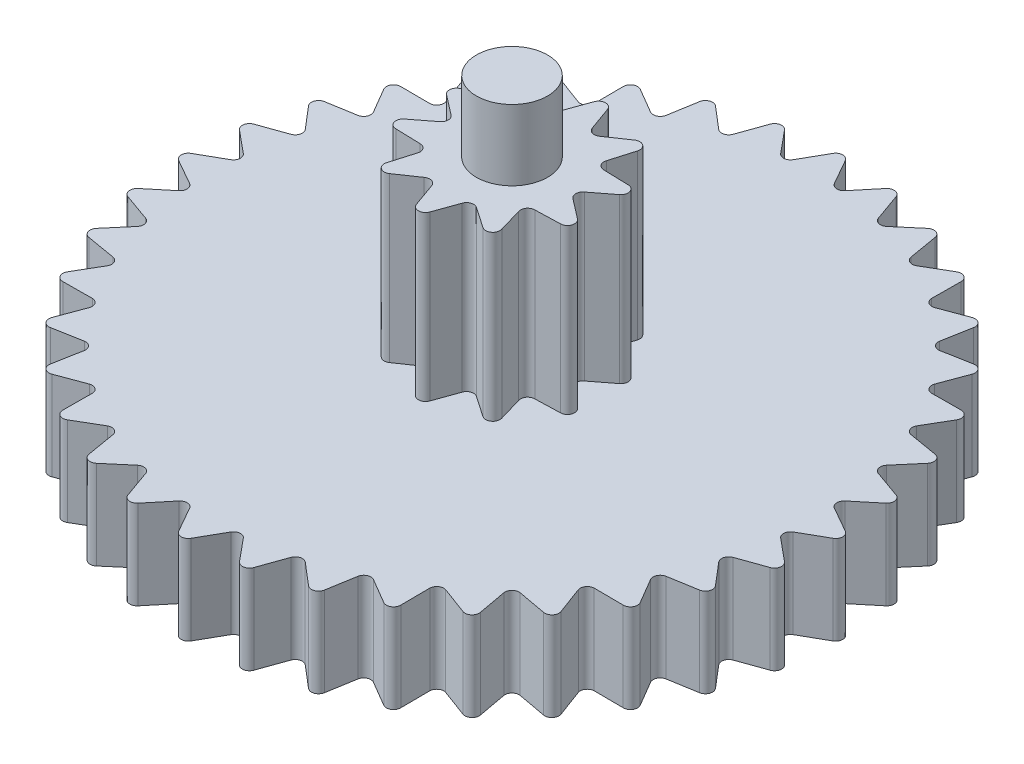
from build123d import *

# Parameters (mm, degrees)
BOSS_EXTRUDE1_DEPTH      = 2.5
SKETCH2_R                = 1
BOSS_EXTRUDE2_DEPTH      = 7.1
SKETCH3_R                = 1
BOSS_EXTRUDE3_DEPTH      = 9.08
BOSS_EXTRUDE3_DEPTH_BACK = 2.6
FILLET1_R                = 1


with BuildPart() as part:
    # Sketch1 → Boss-Extrude1 (new body)
    with BuildSketch(Plane(origin=(0, 0, 0), x_dir=(1, 0, 0), z_dir=(0, 1, 0))):
        with BuildLine():
            Line((1.42370209, 9.08258892), (0.900959127, 8.450813806))
            ThreePointArc((0.900959127, 8.450813806), (0.825205502, 8.397364753), (0.733489057, 8.383818287))
            ThreePointArc((0.733489057, 8.383818287), (0.64551831, 8.413085345), (0.580196884, 8.478876866))
            Line((0.580196884, 8.478876866), (0.175102158, 9.191827259))
            ThreePointArc((0.175102158, 9.191827259), (0, 9.295187545), (-0.175102158, 9.191827259))
            Line((-0.175102158, 9.191827259), (-0.580196884, 8.478876866))
            ThreePointArc((-0.580196884, 8.478876866), (-0.64551831, 8.413085345), (-0.733489057, 8.383818287))
            ThreePointArc((-0.733489057, 8.383818287), (-0.825205502, 8.397364753), (-0.900959127, 8.450813806))
            Line((-0.900959127, 8.450813806), (-1.42370209, 9.08258892))
            ThreePointArc((-1.42370209, 9.08258892), (-1.614092378, 9.15397276), (-1.768586015, 9.021776578))
            Line((-1.768586015, 9.021776578), (-2.043723906, 8.249313543))
            ThreePointArc((-2.043723906, 8.249313543), (-2.096628375, 8.173178596), (-2.178180478, 8.12908021))
            ThreePointArc((-2.178180478, 8.12908021), (-2.270855863, 8.126494482), (-2.35473995, 8.165977045))
            Line((-2.35473995, 8.165977045), (-2.979247871, 8.697380712))
            ThreePointArc((-2.979247871, 8.697380712), (-3.179141376, 8.734619145), (-3.308332282, 8.577603782))
            Line((-3.308332282, 8.577603782), (-3.445153411, 7.769099002))
            ThreePointArc((-3.445153411, 7.769099002), (-3.484033448, 7.684933952), (-3.556688986, 7.627344145))
            ThreePointArc((-3.556688986, 7.627344145), (-3.647507417, 7.608704788), (-3.736973192, 7.633021204))
            Line((-3.736973192, 7.633021204), (-4.444270713, 8.047906992))
            ThreePointArc((-4.444270713, 8.047906992), (-4.647593772, 8.049868547), (-4.747556546, 7.872804835))
            Line((-4.747556546, 7.872804835), (-4.741903674, 7.05282432))
            ThreePointArc((-4.741903674, 7.05282432), (-4.765577928, 6.963186478), (-4.8271293, 6.893855088))
            ThreePointArc((-4.8271293, 6.893855088), (-4.913331304, 6.85972845), (-5.005660395, 6.868139875))
            Line((-5.005660395, 6.868139875), (-5.774256638, 7.153901691))
            ThreePointArc((-5.774256638, 7.153901691), (-5.974831384, 7.120526766), (-6.042528707, 6.928794696))
            Line((-6.042528707, 6.928794696), (-5.894573592, 6.122253139))
            ThreePointArc((-5.894573592, 6.122253139), (-5.902322733, 6.029866106), (-5.950899733, 5.950899733))
            ThreePointArc((-5.950899733, 5.950899733), (-6.029866106, 5.902322733), (-6.122253139, 5.894573592))
            Line((-6.122253139, 5.894573592), (-6.928794696, 6.042528707))
            ThreePointArc((-6.928794696, 6.042528707), (-7.120526766, 5.974831384), (-7.153901691, 5.774256638))
            Line((-7.153901691, 5.774256638), (-6.868139875, 5.005660395))
            ThreePointArc((-6.868139875, 5.005660395), (-6.85972845, 4.913331304), (-6.893855088, 4.8271293))
            ThreePointArc((-6.893855088, 4.8271293), (-6.963186478, 4.765577928), (-7.05282432, 4.741903674))
            Line((-7.05282432, 4.741903674), (-7.872804835, 4.747556546))
            ThreePointArc((-7.872804835, 4.747556546), (-8.049868547, 4.647593772), (-8.047906992, 4.444270713))
            Line((-8.047906992, 4.444270713), (-7.633021204, 3.736973192))
            ThreePointArc((-7.633021204, 3.736973192), (-7.608704788, 3.647507417), (-7.627344145, 3.556688986))
            ThreePointArc((-7.627344145, 3.556688986), (-7.684933952, 3.484033448), (-7.769099002, 3.445153411))
            Line((-7.769099002, 3.445153411), (-8.577603782, 3.308332282))
            ThreePointArc((-8.577603782, 3.308332282), (-8.734619145, 3.179141376), (-8.697380712, 2.979247871))
            Line((-8.697380712, 2.979247871), (-8.165977045, 2.35473995))
            ThreePointArc((-8.165977045, 2.35473995), (-8.126494482, 2.270855863), (-8.12908021, 2.178180478))
            ThreePointArc((-8.12908021, 2.178180478), (-8.173178596, 2.096628375), (-8.249313543, 2.043723906))
            Line((-8.249313543, 2.043723906), (-9.021776578, 1.768586015))
            ThreePointArc((-9.021776578, 1.768586015), (-9.15397276, 1.614092378), (-9.08258892, 1.42370209))
            Line((-9.08258892, 1.42370209), (-8.450813806, 0.900959127))
            ThreePointArc((-8.450813806, 0.900959127), (-8.397364753, 0.825205502), (-8.383818287, 0.733489057))
            ThreePointArc((-8.383818287, 0.733489057), (-8.413085345, 0.64551831), (-8.478876866, 0.580196884))
            Line((-8.478876866, 0.580196884), (-9.191827259, 0.175102158))
            ThreePointArc((-9.191827259, 0.175102158), (-9.295187545, 0), (-9.191827259, -0.175102158))
            Line((-9.191827259, -0.175102158), (-8.478876866, -0.580196884))
            ThreePointArc((-8.478876866, -0.580196884), (-8.413085345, -0.64551831), (-8.383818287, -0.733489057))
            ThreePointArc((-8.383818287, -0.733489057), (-8.397364753, -0.825205502), (-8.450813806, -0.900959127))
            Line((-8.450813806, -0.900959127), (-9.08258892, -1.42370209))
            ThreePointArc((-9.08258892, -1.42370209), (-9.15397276, -1.614092378), (-9.021776578, -1.768586015))
            Line((-9.021776578, -1.768586015), (-8.249313543, -2.043723906))
            ThreePointArc((-8.249313543, -2.043723906), (-8.173178596, -2.096628375), (-8.12908021, -2.178180478))
            ThreePointArc((-8.12908021, -2.178180478), (-8.126494482, -2.270855863), (-8.165977045, -2.35473995))
            Line((-8.165977045, -2.35473995), (-8.697380712, -2.979247871))
            ThreePointArc((-8.697380712, -2.979247871), (-8.734619145, -3.179141376), (-8.577603782, -3.308332282))
            Line((-8.577603782, -3.308332282), (-7.769099002, -3.445153411))
            ThreePointArc((-7.769099002, -3.445153411), (-7.684933952, -3.484033448), (-7.627344145, -3.556688986))
            ThreePointArc((-7.627344145, -3.556688986), (-7.608704788, -3.647507417), (-7.633021204, -3.736973192))
            Line((-7.633021204, -3.736973192), (-8.047906992, -4.444270713))
            ThreePointArc((-8.047906992, -4.444270713), (-8.049868547, -4.647593772), (-7.872804835, -4.747556546))
            Line((-7.872804835, -4.747556546), (-7.05282432, -4.741903674))
            ThreePointArc((-7.05282432, -4.741903674), (-6.963186478, -4.765577928), (-6.893855088, -4.8271293))
            ThreePointArc((-6.893855088, -4.8271293), (-6.85972845, -4.913331304), (-6.868139875, -5.005660395))
            Line((-6.868139875, -5.005660395), (-7.153901691, -5.774256638))
            ThreePointArc((-7.153901691, -5.774256638), (-7.120526766, -5.974831384), (-6.928794696, -6.042528707))
            Line((-6.928794696, -6.042528707), (-6.122253139, -5.894573592))
            ThreePointArc((-6.122253139, -5.894573592), (-6.029866106, -5.902322733), (-5.950899733, -5.950899733))
            ThreePointArc((-5.950899733, -5.950899733), (-5.902322733, -6.029866106), (-5.894573592, -6.122253139))
            Line((-5.894573592, -6.122253139), (-6.042528707, -6.928794696))
            ThreePointArc((-6.042528707, -6.928794696), (-5.974831384, -7.120526766), (-5.774256638, -7.153901691))
            Line((-5.774256638, -7.153901691), (-5.005660395, -6.868139875))
            ThreePointArc((-5.005660395, -6.868139875), (-4.913331304, -6.85972845), (-4.8271293, -6.893855088))
            ThreePointArc((-4.8271293, -6.893855088), (-4.765577928, -6.963186478), (-4.741903674, -7.05282432))
            Line((-4.741903674, -7.05282432), (-4.747556546, -7.872804835))
            ThreePointArc((-4.747556546, -7.872804835), (-4.647593772, -8.049868547), (-4.444270713, -8.047906992))
            Line((-4.444270713, -8.047906992), (-3.736973192, -7.633021204))
            ThreePointArc((-3.736973192, -7.633021204), (-3.647507417, -7.608704788), (-3.556688986, -7.627344145))
            ThreePointArc((-3.556688986, -7.627344145), (-3.484033448, -7.684933952), (-3.445153411, -7.769099002))
            Line((-3.445153411, -7.769099002), (-3.308332282, -8.577603782))
            ThreePointArc((-3.308332282, -8.577603782), (-3.179141376, -8.734619145), (-2.979247871, -8.697380712))
            Line((-2.979247871, -8.697380712), (-2.35473995, -8.165977045))
            ThreePointArc((-2.35473995, -8.165977045), (-2.270855863, -8.126494482), (-2.178180478, -8.12908021))
            ThreePointArc((-2.178180478, -8.12908021), (-2.096628375, -8.173178596), (-2.043723906, -8.249313543))
            Line((-2.043723906, -8.249313543), (-1.768586015, -9.021776578))
            ThreePointArc((-1.768586015, -9.021776578), (-1.614092378, -9.15397276), (-1.42370209, -9.08258892))
            Line((-1.42370209, -9.08258892), (-0.900959127, -8.450813806))
            ThreePointArc((-0.900959127, -8.450813806), (-0.825205502, -8.397364753), (-0.733489057, -8.383818287))
            ThreePointArc((-0.733489057, -8.383818287), (-0.64551831, -8.413085345), (-0.580196884, -8.478876866))
            Line((-0.580196884, -8.478876866), (-0.175102158, -9.191827259))
            ThreePointArc((-0.175102158, -9.191827259), (0, -9.295187545), (0.175102158, -9.191827259))
            Line((0.175102158, -9.191827259), (0.580196884, -8.478876866))
            ThreePointArc((0.580196884, -8.478876866), (0.64551831, -8.413085345), (0.733489057, -8.383818287))
            ThreePointArc((0.733489057, -8.383818287), (0.825205502, -8.397364753), (0.900959127, -8.450813806))
            Line((0.900959127, -8.450813806), (1.42370209, -9.08258892))
            ThreePointArc((1.42370209, -9.08258892), (1.614092378, -9.15397276), (1.768586015, -9.021776578))
            Line((1.768586015, -9.021776578), (2.043723906, -8.249313543))
            ThreePointArc((2.043723906, -8.249313543), (2.096628375, -8.173178596), (2.178180478, -8.12908021))
            ThreePointArc((2.178180478, -8.12908021), (2.270855863, -8.126494482), (2.35473995, -8.165977045))
            Line((2.35473995, -8.165977045), (2.979247871, -8.697380712))
            ThreePointArc((2.979247871, -8.697380712), (3.179141376, -8.734619145), (3.308332282, -8.577603782))
            Line((3.308332282, -8.577603782), (3.445153411, -7.769099002))
            ThreePointArc((3.445153411, -7.769099002), (3.484033448, -7.684933952), (3.556688986, -7.627344145))
            ThreePointArc((3.556688986, -7.627344145), (3.647507417, -7.608704788), (3.736973192, -7.633021204))
            Line((3.736973192, -7.633021204), (4.444270713, -8.047906992))
            ThreePointArc((4.444270713, -8.047906992), (4.647593772, -8.049868547), (4.747556546, -7.872804835))
            Line((4.747556546, -7.872804835), (4.741903674, -7.05282432))
            ThreePointArc((4.741903674, -7.05282432), (4.765577928, -6.963186478), (4.8271293, -6.893855088))
            ThreePointArc((4.8271293, -6.893855088), (4.913331304, -6.85972845), (5.005660395, -6.868139875))
            Line((5.005660395, -6.868139875), (5.774256638, -7.153901691))
            ThreePointArc((5.774256638, -7.153901691), (5.974831384, -7.120526766), (6.042528707, -6.928794696))
            Line((6.042528707, -6.928794696), (5.894573592, -6.122253139))
            ThreePointArc((5.894573592, -6.122253139), (5.902322733, -6.029866106), (5.950899733, -5.950899733))
            ThreePointArc((5.950899733, -5.950899733), (6.029866106, -5.902322733), (6.122253139, -5.894573592))
            Line((6.122253139, -5.894573592), (6.928794696, -6.042528707))
            ThreePointArc((6.928794696, -6.042528707), (7.120526766, -5.974831384), (7.153901691, -5.774256638))
            Line((7.153901691, -5.774256638), (6.868139875, -5.005660395))
            ThreePointArc((6.868139875, -5.005660395), (6.85972845, -4.913331304), (6.893855088, -4.8271293))
            ThreePointArc((6.893855088, -4.8271293), (6.963186478, -4.765577928), (7.05282432, -4.741903674))
            Line((7.05282432, -4.741903674), (7.872804835, -4.747556546))
            ThreePointArc((7.872804835, -4.747556546), (8.049868547, -4.647593772), (8.047906992, -4.444270713))
            Line((8.047906992, -4.444270713), (7.633021204, -3.736973192))
            ThreePointArc((7.633021204, -3.736973192), (7.608704788, -3.647507417), (7.627344145, -3.556688986))
            ThreePointArc((7.627344145, -3.556688986), (7.684933952, -3.484033448), (7.769099002, -3.445153411))
            Line((7.769099002, -3.445153411), (8.577603782, -3.308332282))
            ThreePointArc((8.577603782, -3.308332282), (8.734619145, -3.179141376), (8.697380712, -2.979247871))
            Line((8.697380712, -2.979247871), (8.165977045, -2.35473995))
            ThreePointArc((8.165977045, -2.35473995), (8.126494482, -2.270855863), (8.12908021, -2.178180478))
            ThreePointArc((8.12908021, -2.178180478), (8.173178596, -2.096628375), (8.249313543, -2.043723906))
            Line((8.249313543, -2.043723906), (9.021776578, -1.768586015))
            ThreePointArc((9.021776578, -1.768586015), (9.15397276, -1.614092378), (9.08258892, -1.42370209))
            Line((9.08258892, -1.42370209), (8.450813806, -0.900959127))
            ThreePointArc((8.450813806, -0.900959127), (8.397364753, -0.825205502), (8.383818287, -0.733489057))
            ThreePointArc((8.383818287, -0.733489057), (8.413085345, -0.64551831), (8.478876866, -0.580196884))
            Line((8.478876866, -0.580196884), (9.191827259, -0.175102158))
            ThreePointArc((9.191827259, -0.175102158), (9.295187545, 0), (9.191827259, 0.175102158))
            Line((9.191827259, 0.175102158), (8.478876866, 0.580196884))
            ThreePointArc((8.478876866, 0.580196884), (8.413085345, 0.64551831), (8.383818287, 0.733489057))
            ThreePointArc((8.383818287, 0.733489057), (8.397364753, 0.825205502), (8.450813806, 0.900959127))
            Line((8.450813806, 0.900959127), (9.08258892, 1.42370209))
            ThreePointArc((9.08258892, 1.42370209), (9.15397276, 1.614092378), (9.021776578, 1.768586015))
            Line((9.021776578, 1.768586015), (8.249313543, 2.043723906))
            ThreePointArc((8.249313543, 2.043723906), (8.173178596, 2.096628375), (8.12908021, 2.178180478))
            ThreePointArc((8.12908021, 2.178180478), (8.126494482, 2.270855863), (8.165977045, 2.35473995))
            Line((8.165977045, 2.35473995), (8.697380712, 2.979247871))
            ThreePointArc((8.697380712, 2.979247871), (8.734619145, 3.179141376), (8.577603782, 3.308332282))
            Line((8.577603782, 3.308332282), (7.769099002, 3.445153411))
            ThreePointArc((7.769099002, 3.445153411), (7.684933952, 3.484033448), (7.627344145, 3.556688986))
            ThreePointArc((7.627344145, 3.556688986), (7.608704788, 3.647507417), (7.633021204, 3.736973192))
            Line((7.633021204, 3.736973192), (8.047906992, 4.444270713))
            ThreePointArc((8.047906992, 4.444270713), (8.049868547, 4.647593772), (7.872804835, 4.747556546))
            Line((7.872804835, 4.747556546), (7.05282432, 4.741903674))
            ThreePointArc((7.05282432, 4.741903674), (6.963186478, 4.765577928), (6.893855088, 4.8271293))
            ThreePointArc((6.893855088, 4.8271293), (6.85972845, 4.913331304), (6.868139875, 5.005660395))
            Line((6.868139875, 5.005660395), (7.153901691, 5.774256638))
            ThreePointArc((7.153901691, 5.774256638), (7.120526766, 5.974831384), (6.928794696, 6.042528707))
            Line((6.928794696, 6.042528707), (6.122253139, 5.894573592))
            ThreePointArc((6.122253139, 5.894573592), (6.029866106, 5.902322733), (5.950899733, 5.950899733))
            ThreePointArc((5.950899733, 5.950899733), (5.902322733, 6.029866106), (5.894573592, 6.122253139))
            Line((5.894573592, 6.122253139), (6.042528707, 6.928794696))
            ThreePointArc((6.042528707, 6.928794696), (5.974831384, 7.120526766), (5.774256638, 7.153901691))
            Line((5.774256638, 7.153901691), (5.005660395, 6.868139875))
            ThreePointArc((5.005660395, 6.868139875), (4.913331304, 6.85972845), (4.8271293, 6.893855088))
            ThreePointArc((4.8271293, 6.893855088), (4.765577928, 6.963186478), (4.741903674, 7.05282432))
            Line((4.741903674, 7.05282432), (4.747556546, 7.872804835))
            ThreePointArc((4.747556546, 7.872804835), (4.647593772, 8.049868547), (4.444270713, 8.047906992))
            Line((4.444270713, 8.047906992), (3.736973192, 7.633021204))
            ThreePointArc((3.736973192, 7.633021204), (3.647507417, 7.608704788), (3.556688986, 7.627344145))
            ThreePointArc((3.556688986, 7.627344145), (3.484033448, 7.684933952), (3.445153411, 7.769099002))
            Line((3.445153411, 7.769099002), (3.308332282, 8.577603782))
            ThreePointArc((3.308332282, 8.577603782), (3.179141376, 8.734619145), (2.979247871, 8.697380712))
            Line((2.979247871, 8.697380712), (2.35473995, 8.165977045))
            ThreePointArc((2.35473995, 8.165977045), (2.270855863, 8.126494482), (2.178180478, 8.12908021))
            ThreePointArc((2.178180478, 8.12908021), (2.096628375, 8.173178596), (2.043723906, 8.249313543))
            Line((2.043723906, 8.249313543), (1.768586015, 9.021776578))
            ThreePointArc((1.768586015, 9.021776578), (1.614092378, 9.15397276), (1.42370209, 9.08258892))
        make_face()
        with BuildLine():
            Line((-0.189393176, 2.492919805), (-0.425136188, 1.833810381))
            ThreePointArc((-0.425136188, 1.833810381), (-0.473882898, 1.753634678), (-0.55383033, 1.704514488))
            ThreePointArc((-0.55383033, 1.704514488), (-0.647381284, 1.697261635), (-0.733944297, 1.733472544))
            Line((-0.733944297, 1.733472544), (-1.312079198, 2.128137003))
            ThreePointArc((-1.312079198, 2.128137003), (-1.545083454, 2.126624932), (-1.618523794, 1.905491972))
            Line((-1.618523794, 1.905491972), (-1.421829099, 1.233694981))
            ThreePointArc((-1.421829099, 1.233694981), (-1.41413992, 1.140178878), (-1.449946627, 1.053447888))
            ThreePointArc((-1.449946627, 1.053447888), (-1.521367819, 0.992592335), (-1.612683006, 0.971007114))
            Line((-1.612683006, 0.971007114), (-2.312381915, 0.950478199))
            ThreePointArc((-2.312381915, 0.950478199), (-2.499997545, 0.812298443), (-2.429433335, 0.590230971))
            Line((-2.429433335, 0.590230971), (-1.87543162, 0.16235003))
            ThreePointArc((-1.87543162, 0.16235003), (-1.814243557, 0.0912135), (-1.792232594, 0))
            ThreePointArc((-1.792232594, 0), (-1.814243557, -0.0912135), (-1.87543162, -0.16235003))
            Line((-1.87543162, -0.16235003), (-2.429433335, -0.590230971))
            ThreePointArc((-2.429433335, -0.590230971), (-2.499997545, -0.812298443), (-2.312381915, -0.950478199))
            Line((-2.312381915, -0.950478199), (-1.612683006, -0.971007114))
            ThreePointArc((-1.612683006, -0.971007114), (-1.521367819, -0.992592335), (-1.449946627, -1.053447888))
            ThreePointArc((-1.449946627, -1.053447888), (-1.41413992, -1.140178878), (-1.421829099, -1.233694981))
            Line((-1.421829099, -1.233694981), (-1.618523794, -1.905491972))
            ThreePointArc((-1.618523794, -1.905491972), (-1.545083454, -2.126624932), (-1.312079198, -2.128137003))
            Line((-1.312079198, -2.128137003), (-0.733944297, -1.733472544))
            ThreePointArc((-0.733944297, -1.733472544), (-0.647381284, -1.697261635), (-0.55383033, -1.704514488))
            ThreePointArc((-0.55383033, -1.704514488), (-0.473882898, -1.753634678), (-0.425136188, -1.833810381))
            Line((-0.425136188, -1.833810381), (-0.189393176, -2.492919805))
            ThreePointArc((-0.189393176, -2.492919805), (0, -2.628652979), (0.189393176, -2.492919805))
            Line((0.189393176, -2.492919805), (0.425136188, -1.833810381))
            ThreePointArc((0.425136188, -1.833810381), (0.473882898, -1.753634678), (0.55383033, -1.704514488))
            ThreePointArc((0.55383033, -1.704514488), (0.647381284, -1.697261635), (0.733944297, -1.733472544))
            Line((0.733944297, -1.733472544), (1.312079198, -2.128137003))
            ThreePointArc((1.312079198, -2.128137003), (1.545083454, -2.126624932), (1.618523794, -1.905491972))
            Line((1.618523794, -1.905491972), (1.421829099, -1.233694981))
            ThreePointArc((1.421829099, -1.233694981), (1.41413992, -1.140178878), (1.449946627, -1.053447888))
            ThreePointArc((1.449946627, -1.053447888), (1.521367819, -0.992592335), (1.612683006, -0.971007114))
            Line((1.612683006, -0.971007114), (2.312381915, -0.950478199))
            ThreePointArc((2.312381915, -0.950478199), (2.499997545, -0.812298443), (2.429433335, -0.590230971))
            Line((2.429433335, -0.590230971), (1.87543162, -0.16235003))
            ThreePointArc((1.87543162, -0.16235003), (1.814243557, -0.0912135), (1.792232594, 0))
            ThreePointArc((1.792232594, 0), (1.814243557, 0.0912135), (1.87543162, 0.16235003))
            Line((1.87543162, 0.16235003), (2.429433335, 0.590230971))
            ThreePointArc((2.429433335, 0.590230971), (2.499997545, 0.812298443), (2.312381915, 0.950478199))
            Line((2.312381915, 0.950478199), (1.612683006, 0.971007114))
            ThreePointArc((1.612683006, 0.971007114), (1.521367819, 0.992592335), (1.449946627, 1.053447888))
            ThreePointArc((1.449946627, 1.053447888), (1.41413992, 1.140178878), (1.421829099, 1.233694981))
            Line((1.421829099, 1.233694981), (1.618523794, 1.905491972))
            ThreePointArc((1.618523794, 1.905491972), (1.545083454, 2.126624932), (1.312079198, 2.128137003))
            Line((1.312079198, 2.128137003), (0.733944297, 1.733472544))
            ThreePointArc((0.733944297, 1.733472544), (0.647381284, 1.697261635), (0.55383033, 1.704514488))
            ThreePointArc((0.55383033, 1.704514488), (0.473882898, 1.753634678), (0.425136188, 1.833810381))
            Line((0.425136188, 1.833810381), (0.189393176, 2.492919805))
            ThreePointArc((0.189393176, 2.492919805), (0, 2.628652979), (-0.189393176, 2.492919805))
        make_face(mode=Mode.SUBTRACT)
    extrude(amount=BOSS_EXTRUDE1_DEPTH)

    # Sketch2 → Boss-Extrude2 (add)
    with BuildSketch(Plane(origin=(0, 0, 0), x_dir=(1, 0, 0), z_dir=(0, 1, 0))):
        with BuildLine():
            Line((-2.429433335, 0.590230971), (-1.87543162, 0.16235003))
            ThreePointArc((-1.87543162, 0.16235003), (-1.792232594, 0), (-1.87543162, -0.16235003))
            Line((-1.87543162, -0.16235003), (-2.429433335, -0.590230971))
            ThreePointArc((-2.429433335, -0.590230971), (-2.499997545, -0.812298443), (-2.312381915, -0.950478199))
            Line((-2.312381915, -0.950478199), (-1.612683006, -0.971007114))
            ThreePointArc((-1.612683006, -0.971007114), (-1.449946627, -1.053447888), (-1.421829099, -1.233694981))
            Line((-1.421829099, -1.233694981), (-1.618523794, -1.905491972))
            ThreePointArc((-1.618523794, -1.905491972), (-1.545083454, -2.126624932), (-1.312079198, -2.128137003))
            Line((-1.312079198, -2.128137003), (-0.733944297, -1.733472544))
            ThreePointArc((-0.733944297, -1.733472544), (-0.55383033, -1.704514488), (-0.425136188, -1.833810381))
            Line((-0.425136188, -1.833810381), (-0.189393176, -2.492919805))
            ThreePointArc((-0.189393176, -2.492919805), (0, -2.628652979), (0.189393176, -2.492919805))
            Line((0.189393176, -2.492919805), (0.425136188, -1.833810381))
            ThreePointArc((0.425136188, -1.833810381), (0.55383033, -1.704514488), (0.733944297, -1.733472544))
            Line((0.733944297, -1.733472544), (1.312079198, -2.128137003))
            ThreePointArc((1.312079198, -2.128137003), (1.545083454, -2.126624932), (1.618523794, -1.905491972))
            Line((1.618523794, -1.905491972), (1.421829099, -1.233694981))
            ThreePointArc((1.421829099, -1.233694981), (1.449946627, -1.053447888), (1.612683006, -0.971007114))
            Line((1.612683006, -0.971007114), (2.312381915, -0.950478199))
            ThreePointArc((2.312381915, -0.950478199), (2.499997545, -0.812298443), (2.429433335, -0.590230971))
            Line((2.429433335, -0.590230971), (1.87543162, -0.16235003))
            ThreePointArc((1.87543162, -0.16235003), (1.792232594, 0), (1.87543162, 0.16235003))
            Line((1.87543162, 0.16235003), (2.429433335, 0.590230971))
            ThreePointArc((2.429433335, 0.590230971), (2.499997545, 0.812298443), (2.312381915, 0.950478199))
            Line((2.312381915, 0.950478199), (1.612683006, 0.971007114))
            ThreePointArc((1.612683006, 0.971007114), (1.449946627, 1.053447888), (1.421829099, 1.233694981))
            Line((1.421829099, 1.233694981), (1.618523794, 1.905491972))
            ThreePointArc((1.618523794, 1.905491972), (1.545083454, 2.126624932), (1.312079198, 2.128137003))
            Line((1.312079198, 2.128137003), (0.733944297, 1.733472544))
            ThreePointArc((0.733944297, 1.733472544), (0.55383033, 1.704514488), (0.425136188, 1.833810381))
            Line((0.425136188, 1.833810381), (0.189393176, 2.492919805))
            ThreePointArc((0.189393176, 2.492919805), (0, 2.628652979), (-0.189393176, 2.492919805))
            Line((-0.189393176, 2.492919805), (-0.425136188, 1.833810381))
            ThreePointArc((-0.425136188, 1.833810381), (-0.55383033, 1.704514488), (-0.733944297, 1.733472544))
            Line((-0.733944297, 1.733472544), (-1.312079198, 2.128137003))
            ThreePointArc((-1.312079198, 2.128137003), (-1.545083454, 2.126624932), (-1.618523794, 1.905491972))
            Line((-1.618523794, 1.905491972), (-1.421829099, 1.233694981))
            ThreePointArc((-1.421829099, 1.233694981), (-1.449946627, 1.053447888), (-1.612683006, 0.971007114))
            Line((-1.612683006, 0.971007114), (-2.312381915, 0.950478199))
            ThreePointArc((-2.312381915, 0.950478199), (-2.499997545, 0.812298443), (-2.429433335, 0.590230971))
        make_face()
        Circle(SKETCH2_R, mode=Mode.SUBTRACT)
    extrude(amount=BOSS_EXTRUDE2_DEPTH)

    # Sketch3 → Boss-Extrude3 (add, two sides)
    with BuildSketch(Plane(origin=(0, 0, 0), x_dir=(1, 0, 0), z_dir=(0, 1, 0))) as boss_extrude3_sk:
        Circle(SKETCH3_R)
    extrude(amount=BOSS_EXTRUDE3_DEPTH)
    extrude(boss_extrude3_sk.sketch, amount=-BOSS_EXTRUDE3_DEPTH_BACK)

    # Fillet1
    fillet1_edges = [part.edges().sort_by_distance(p)[0] for p in [
        (-1, -2.6, 0),
    ]]
    fillet(fillet1_edges, radius=FILLET1_R)


solid = part.part
